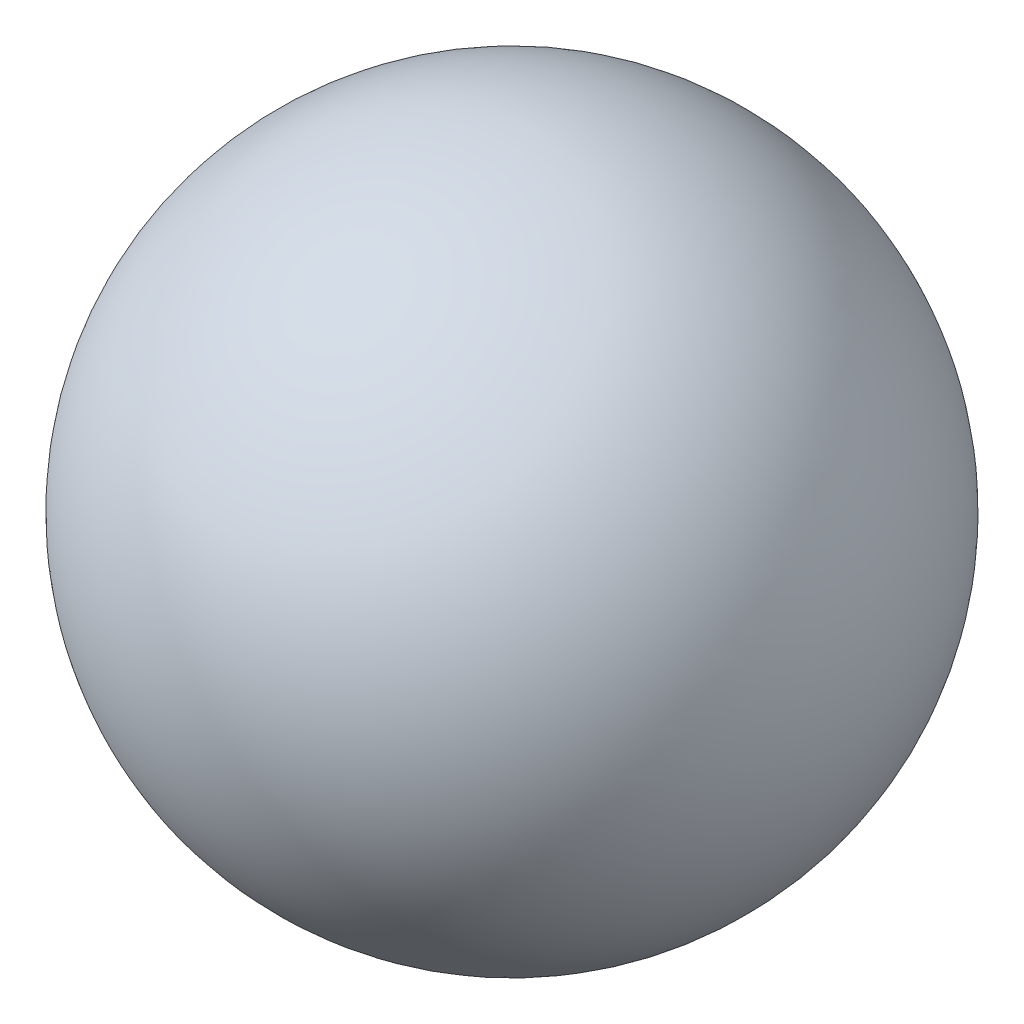
from build123d import *


with BuildPart() as part:
    # Sketch1 → Revolve1 (revolve)
    with BuildSketch(Plane(origin=(0, 0, 0), x_dir=(1, 0, 0), z_dir=(0, 1, 0))):
        with BuildLine():
            Line((0, 44.442867879), (0, -44.442867879))
            ThreePointArc((0, -44.442867879), (44.442867879, 0), (0, 44.442867879))
        make_face()
    revolve(axis=Axis((0, 0, -44.442867879), (0, 0, 1)))


solid = part.part
